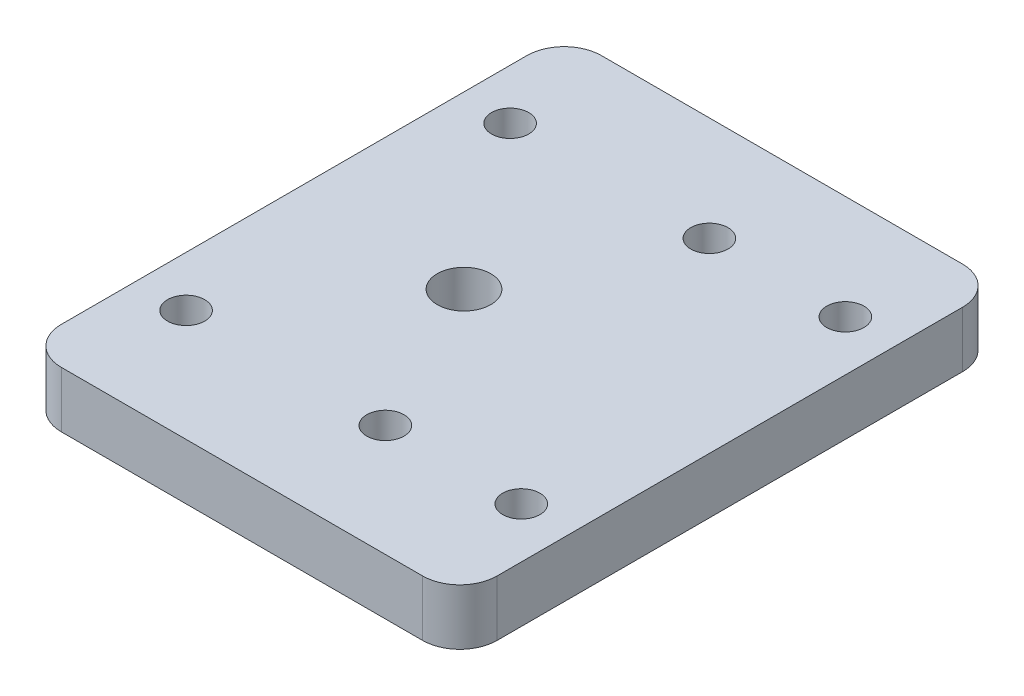
from build123d import *

# Parameters (mm, degrees)
BOSS_EXTRUDE1_DEPTH   = 3
BOSS_EXTRUDE1_2_DEPTH = 3
SKETCH1_W             = 23.4
SKETCH1_H             = 29
SKETCH1_R             = 1
BOSS_EXTRUDE1_3_DEPTH = 3
FILLET1_R             = 2
SKETCH5_R             = 1.44
CUT_EXTRUDE3_DEPTH    = 10
CUT_EXTRUDE4_DEPTH    = 10
SKETCH8_R             = 1
CUT_EXTRUDE5_DEPTH    = 10
SKETCH9_R             = 3.026992654
BOSS_EXTRUDE3_DEPTH   = 3
SKETCH10_R            = 1.44
CUT_EXTRUDE6_DEPTH    = 3.5


with BuildPart() as part:
    # Sketch1 → Boss-Extrude1 (new body)
    with BuildSketch(Plane(origin=(0, 0, 0), x_dir=(1, 0, 0), z_dir=(0, 1, 0))):
        with BuildLine():
            add(Edge.make_bspline(
                [(19.180993887, -14.242526212), (19.80083761, -12.341053413), (17.899318471, -11.721194585), (17.279474749, -13.622667384), (16.659631026, -15.524140184), (18.561150164, -16.143999012), (19.180993887, -14.242526212)],
                knots=[0, 0, 0, 0, 0.5, 0.5, 0.5, 1, 1, 1, 1], degree=3, weights=[1, 0.333333333, 0.333333333, 1, 0.333333333, 0.333333333, 1]))
        make_face()
    extrude(amount=BOSS_EXTRUDE1_DEPTH)


with BuildPart() as body_2:
    # Sketch1 → Boss-Extrude1 2 (new body)
    with BuildSketch(Plane(origin=(0, 0, 0), x_dir=(1, 0, 0), z_dir=(0, 1, 0))):
        with BuildLine():
            add(Edge.make_bspline(
                [(22.488505608, -4.096188772), (23.108349331, -2.194715972), (21.206830193, -1.574857144), (20.58698647, -3.476329943), (19.967142747, -5.377802743), (21.868661885, -5.997661571), (22.488505608, -4.096188772)],
                knots=[0, 0, 0, 0, 0.5, 0.5, 0.5, 1, 1, 1, 1], degree=3, weights=[1, 0.333333333, 0.333333333, 1, 0.333333333, 0.333333333, 1]))
        make_face()
    extrude(amount=BOSS_EXTRUDE1_2_DEPTH)


with BuildPart() as body_3:
    # Sketch1 → Boss-Extrude1 3 (new body)
    with BuildSketch(Plane(origin=(0, 0, 0), x_dir=(1, 0, 0), z_dir=(0, 1, 0))):
        Rectangle(SKETCH1_W, SKETCH1_H)
        with Locations(Location((9, 8.9, 0), (0, 0, 270))):
            Circle(SKETCH1_R, mode=Mode.SUBTRACT)
        with Locations(Location((9, -8.5, 0), (0, 0, 90))):
            Circle(SKETCH1_R, mode=Mode.SUBTRACT)
        with Locations(Location((-9, -8.5, 0), (0, 0, 90))):
            Circle(SKETCH1_R, mode=Mode.SUBTRACT)
        with Locations(Location((1.7, -8.5, 0), (0, 0, 90))):
            Circle(SKETCH1_R, mode=Mode.SUBTRACT)
    extrude(amount=BOSS_EXTRUDE1_3_DEPTH)

    # Fillet1
    fillet1_edges = [body_3.edges().sort_by_distance(p)[0] for p in [
        (11.7, 1.5, 14.5),
        (-11.7, 1.5, 14.5),
        (-11.7, 1.5, -14.5),
        (11.7, 1.5, -14.5),
    ]]
    fillet(fillet1_edges, radius=FILLET1_R)

    # Sketch5 → Cut-Extrude3 (cut)
    with BuildSketch(Plane.XZ):
        with Locations(Location((-2.145634177, 3.61037734, 0), (0, 0, 270))):
            Circle(SKETCH5_R)
    extrude(amount=-CUT_EXTRUDE3_DEPTH, mode=Mode.SUBTRACT)

    # Sketch8 → Cut-Extrude5 (cut)
    with BuildSketch(Plane(origin=(0, 3, 0), x_dir=(1, 0, 0), z_dir=(0, 1, 0))):
        with Locations(Location((1.7, 8.9, 0), (0, 0, 270))):
            Circle(SKETCH8_R)
        with Locations(Location((-9, 8.9, 0), (0, 0, 270))):
            Circle(SKETCH8_R)
    extrude(amount=-CUT_EXTRUDE5_DEPTH, mode=Mode.SUBTRACT)

    # Sketch9 → Boss-Extrude3 (add)
    with BuildSketch(Plane(origin=(0, 3, 0), x_dir=(1, 0, 0), z_dir=(0, 1, 0))):
        with Locations((-2.145634177, -3.61037734)):
            Circle(SKETCH9_R)
    extrude(amount=-BOSS_EXTRUDE3_DEPTH)

    # Sketch10 → Cut-Extrude6 (cut)
    with BuildSketch(Plane(origin=(0, 3, 0), x_dir=(1, 0, 0), z_dir=(0, 1, 0))):
        with Locations(Location((-2.523984187, -0.0532018, 0), (0, 0, 270))):
            Circle(SKETCH10_R)
    extrude(amount=-CUT_EXTRUDE6_DEPTH, mode=Mode.SUBTRACT)


with BuildPart() as cut_extrude4_tool:
    # Sketch7 → Cut-Extrude4 (new body)
    with BuildSketch(Plane(origin=(0, 3, 0), x_dir=(1, 0, 0), z_dir=(0, 1, 0))):
        with BuildLine():
            add(Edge.make_bspline(
                [(19.180993887, -14.242526212), (19.80083761, -12.341053413), (17.899318471, -11.721194585), (17.279474749, -13.622667384), (16.659631026, -15.524140184), (18.561150164, -16.143999012), (19.180993887, -14.242526212)],
                knots=[0, 0, 0, 0, 0.5, 0.5, 0.5, 1, 1, 1, 1], degree=3, weights=[1, 0.333333333, 0.333333333, 1, 0.333333333, 0.333333333, 1]))
        make_face()
        with BuildLine():
            add(Edge.make_bspline(
                [(22.488505608, -4.096188772), (23.108349331, -2.194715972), (21.206830193, -1.574857144), (20.58698647, -3.476329943), (19.967142747, -5.377802743), (21.868661885, -5.997661571), (22.488505608, -4.096188772)],
                knots=[0, 0, 0, 0, 0.5, 0.5, 0.5, 1, 1, 1, 1], degree=3, weights=[1, 0.333333333, 0.333333333, 1, 0.333333333, 0.333333333, 1]))
        make_face()
    extrude(amount=-CUT_EXTRUDE4_DEPTH)


with BuildPart() as part_1:
    add(part.part)

    # Cut-Extrude4: cut by cut_extrude4_tool
    add(cut_extrude4_tool.part, mode=Mode.SUBTRACT)


with BuildPart() as body_2_1:
    add(body_2.part)

    # Cut-Extrude4: cut by cut_extrude4_tool
    add(cut_extrude4_tool.part, mode=Mode.SUBTRACT)


solid = body_3.part
